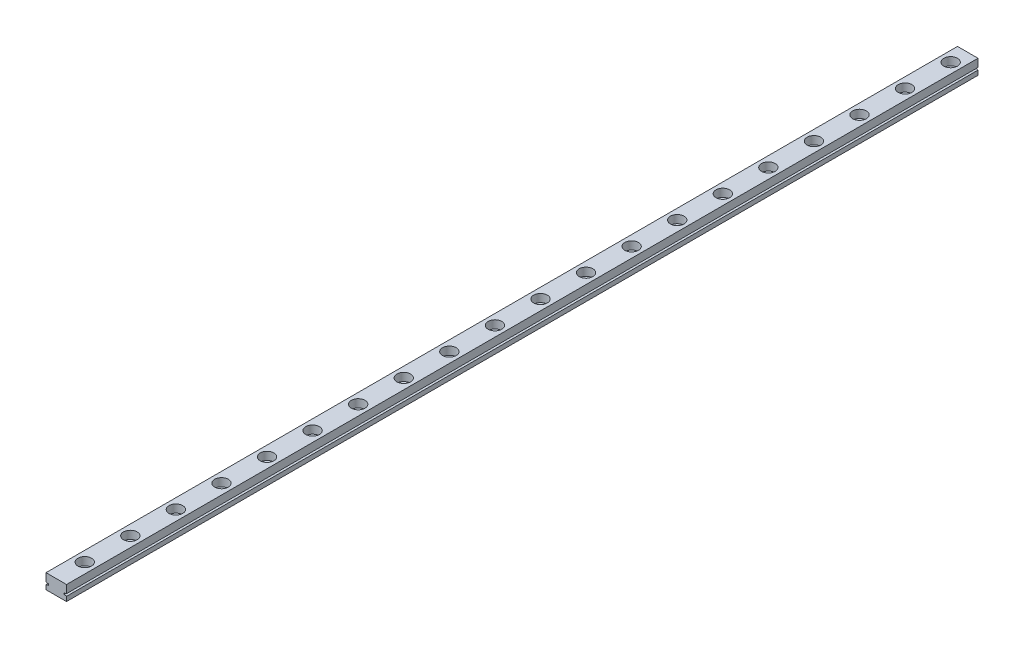
from build123d import *

# Parameters (mm, degrees)
SKETCH_1_W          = 9
SKETCH_1_H          = 6.5
EXTRUDE_1_DEPTH     = 400
SKETCH_2_R          = 1.75
CUT_EXTRUDE_1_DEPTH = 7.5
SKETCH_3_R          = 3
CUT_EXTRUDE_2_DEPTH = 3.5
CUT_EXTRUDE_3_DEPTH = 401
SKETCH_5_R          = 1.75
CUT_EXTRUDE_4_DEPTH = 10


with BuildPart() as part:
    # 草图1 → 凸台-拉伸1 (new body)
    with BuildSketch(Plane.XY):
        Rectangle(SKETCH_1_W, SKETCH_1_H)
    extrude(amount=EXTRUDE_1_DEPTH)

    # 草图2 → 切除-拉伸1 (cut, through all)
    with BuildSketch(Plane(origin=(0, 3.25, 0), x_dir=(1, 0, 0), z_dir=(0, 1, 0))):
        with Locations((0, -7.5)):
            Circle(SKETCH_2_R)
        with Locations((0, -27.5)):
            Circle(SKETCH_2_R)
        with Locations((0, -47.5)):
            Circle(SKETCH_2_R)
        with Locations((0, -67.5)):
            Circle(SKETCH_2_R)
        with Locations((0, -87.5)):
            Circle(SKETCH_2_R)
        with Locations((0, -107.5)):
            Circle(SKETCH_2_R)
        with Locations((0, -127.5)):
            Circle(SKETCH_2_R)
        with Locations((0, -147.5)):
            Circle(SKETCH_2_R)
        with Locations((0, -167.5)):
            Circle(SKETCH_2_R)
        with Locations((0, -187.5)):
            Circle(SKETCH_2_R)
        with Locations((0, -207.5)):
            Circle(SKETCH_2_R)
        with Locations((0, -227.5)):
            Circle(SKETCH_2_R)
        with Locations((0, -247.5)):
            Circle(SKETCH_2_R)
        with Locations((0, -267.5)):
            Circle(SKETCH_2_R)
        with Locations((0, -287.5)):
            Circle(SKETCH_2_R)
        with Locations((0, -307.5)):
            Circle(SKETCH_2_R)
        with Locations((0, -327.5)):
            Circle(SKETCH_2_R)
        with Locations((0, -347.5)):
            Circle(SKETCH_2_R)
        with Locations((0, -367.5)):
            Circle(SKETCH_2_R)
    extrude(amount=-CUT_EXTRUDE_1_DEPTH, mode=Mode.SUBTRACT)

    # 草图3 → 切除-拉伸2 (cut)
    with BuildSketch(Plane(origin=(0, 3.25, 0), x_dir=(1, 0, 0), z_dir=(0, 1, 0))):
        with Locations((0, -7.5)):
            Circle(SKETCH_3_R)
        with Locations((0, -27.5)):
            Circle(SKETCH_3_R)
        with Locations((0, -47.5)):
            Circle(SKETCH_3_R)
        with Locations((0, -67.5)):
            Circle(SKETCH_3_R)
        with Locations((0, -87.5)):
            Circle(SKETCH_3_R)
        with Locations((0, -107.5)):
            Circle(SKETCH_3_R)
        with Locations((0, -127.5)):
            Circle(SKETCH_3_R)
        with Locations((0, -147.5)):
            Circle(SKETCH_3_R)
        with Locations((0, -167.5)):
            Circle(SKETCH_3_R)
        with Locations((0, -187.5)):
            Circle(SKETCH_3_R)
        with Locations((0, -207.5)):
            Circle(SKETCH_3_R)
        with Locations((0, -227.5)):
            Circle(SKETCH_3_R)
        with Locations((0, -247.5)):
            Circle(SKETCH_3_R)
        with Locations((0, -267.5)):
            Circle(SKETCH_3_R)
        with Locations((0, -287.5)):
            Circle(SKETCH_3_R)
        with Locations((0, -307.5)):
            Circle(SKETCH_3_R)
        with Locations((0, -327.5)):
            Circle(SKETCH_3_R)
        with Locations((0, -347.5)):
            Circle(SKETCH_3_R)
        with Locations((0, -367.5)):
            Circle(SKETCH_3_R)
        with Locations((0, -387.5)):
            Circle(SKETCH_3_R)
    extrude(amount=-CUT_EXTRUDE_2_DEPTH, mode=Mode.SUBTRACT)

    # 草图4 → 切除-拉伸3 (cut, through all)
    with BuildSketch(Plane(origin=(0, 0, 0), x_dir=(-1, 0, 0), z_dir=(0, 0, -1))):
        Polygon((4.5, -0.25), (3.5, -0.45), (3.5, -1.05), (4.5, -1.25), align=None)
        Polygon((-4.5, -0.25), (-3.5, -0.45), (-3.5, -1.05), (-4.5, -1.25), align=None)
    extrude(amount=-CUT_EXTRUDE_3_DEPTH, mode=Mode.SUBTRACT)

    # 草图5 → 切除-拉伸4 (cut)
    with BuildSketch(Plane(origin=(0, -0.25, 0), x_dir=(1, 0, 0), z_dir=(0, 1, 0))):
        with Locations((0, -387.5)):
            Circle(SKETCH_5_R)
    extrude(amount=-CUT_EXTRUDE_4_DEPTH, mode=Mode.SUBTRACT)


solid = part.part
